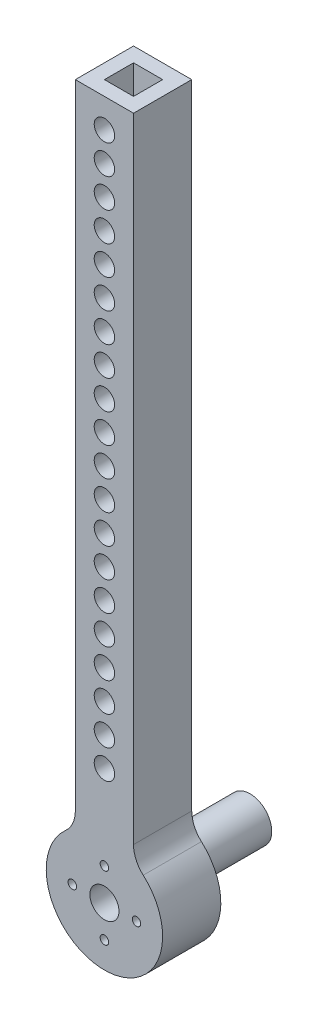
from build123d import *

# Parameters (mm, degrees)
SKETCH1_W           = 12.7
SKETCH1_H           = 12.7
SKETCH1_W_2         = 6.35
SKETCH1_H_2         = 6.35
BOSS_EXTRUDE1_DEPTH = 152.4
SKETCH2_R           = 2.226999991
CUT_EXTRUDE1_DEPTH  = 13.7
SKETCH3_R           = 12.7
BOSS_EXTRUDE2_DEPTH = 12.7
SKETCH4_R           = 4.7625
BOSS_EXTRUDE3_DEPTH = 31.75
SKETCH6_R           = 3.175
SKETCH6_R_2         = 0.927000051
CUT_EXTRUDE3_DEPTH  = 32.75
FILLET2_R           = 6.35


with BuildPart() as part:
    # Sketch1 → Boss-Extrude1 (new body)
    with BuildSketch(Plane(origin=(0, 0, 0), x_dir=(1, 0, 0), z_dir=(0, 1, 0))):
        Rectangle(SKETCH1_W, SKETCH1_H)
        Rectangle(SKETCH1_W_2, SKETCH1_H_2, mode=Mode.SUBTRACT)
    extrude(amount=BOSS_EXTRUDE1_DEPTH)

    # Sketch2 → Cut-Extrude1 (cut, through all)
    with BuildSketch(Plane.XY.offset(6.35)):
        with Locations((0, 25.4)):
            Circle(SKETCH2_R)
        with Locations((0, 31.75)):
            Circle(SKETCH2_R)
        with Locations((0, 38.1)):
            Circle(SKETCH2_R)
        with Locations((0, 44.45)):
            Circle(SKETCH2_R)
        with Locations((0, 50.8)):
            Circle(SKETCH2_R)
        with Locations((0, 57.15)):
            Circle(SKETCH2_R)
        with Locations((0, 63.5)):
            Circle(SKETCH2_R)
        with Locations((0, 69.85)):
            Circle(SKETCH2_R)
        with Locations((0, 76.2)):
            Circle(SKETCH2_R)
        with Locations((0, 82.55)):
            Circle(SKETCH2_R)
        with Locations((0, 88.9)):
            Circle(SKETCH2_R)
        with Locations((0, 95.25)):
            Circle(SKETCH2_R)
        with Locations((0, 101.6)):
            Circle(SKETCH2_R)
        with Locations((0, 107.95)):
            Circle(SKETCH2_R)
        with Locations((0, 114.3)):
            Circle(SKETCH2_R)
        with Locations((0, 120.65)):
            Circle(SKETCH2_R)
        with Locations((0, 127)):
            Circle(SKETCH2_R)
        with Locations((0, 133.35)):
            Circle(SKETCH2_R)
        with Locations((0, 139.7)):
            Circle(SKETCH2_R)
        with Locations((0, 146.05)):
            Circle(SKETCH2_R)
    extrude(amount=-CUT_EXTRUDE1_DEPTH, mode=Mode.SUBTRACT)

    # Sketch3 → Boss-Extrude2 (add)
    with BuildSketch(Plane.XY.offset(6.35)):
        Circle(SKETCH3_R)
    extrude(amount=-BOSS_EXTRUDE2_DEPTH)

    # Sketch4 → Boss-Extrude3 (add)
    with BuildSketch(Plane.XY.offset(6.35)):
        Circle(SKETCH4_R)
    extrude(amount=-BOSS_EXTRUDE3_DEPTH)

    # Sketch6 → Cut-Extrude3 (cut, through all)
    with BuildSketch(Plane.XY.offset(6.35)):
        Circle(SKETCH6_R)
        with Locations((6.99999997, 0)):
            Circle(SKETCH6_R_2)
        with Locations((0, -6.99999997)):
            Circle(SKETCH6_R_2)
        with Locations((-6.99999997, 0)):
            Circle(SKETCH6_R_2)
        with Locations((0, 6.99999997)):
            Circle(SKETCH6_R_2)
    extrude(amount=-CUT_EXTRUDE3_DEPTH, mode=Mode.SUBTRACT)

    # Fillet2
    fillet2_edges = [part.edges().sort_by_distance(p)[0] for p in [
        (6.35, 10.998522628, 0),
        (-6.35, 10.998522628, 0),
    ]]
    fillet(fillet2_edges, radius=FILLET2_R)


solid = part.part
